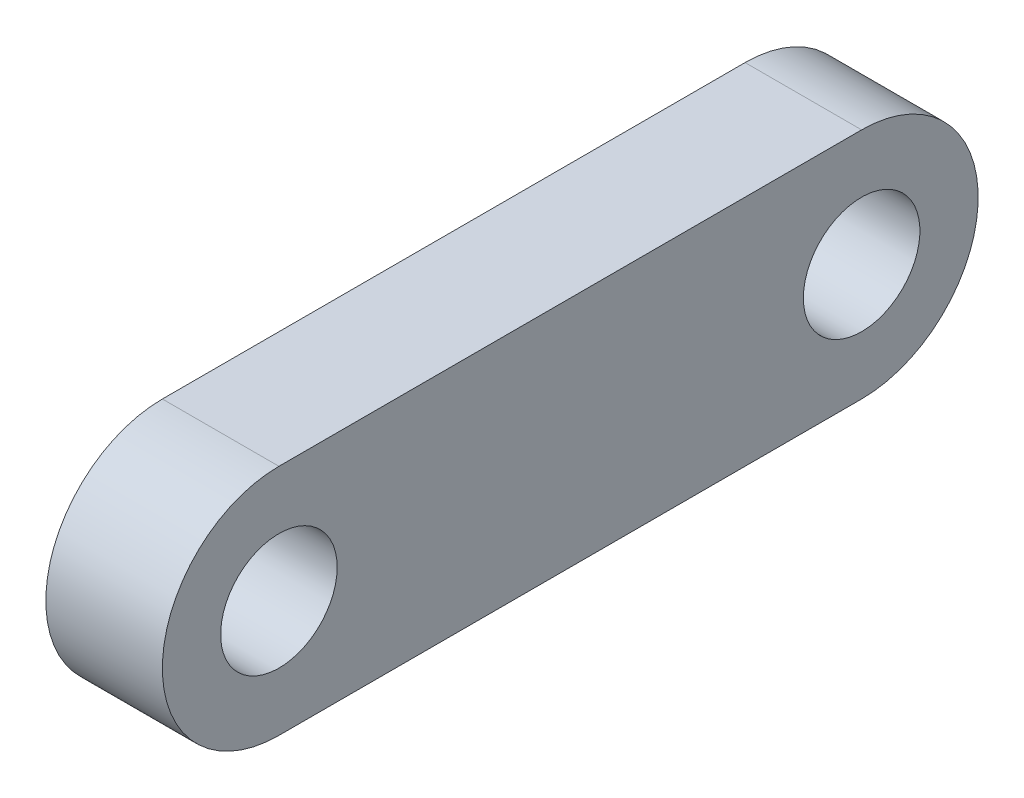
from build123d import *

# Parameters (mm, degrees)
SKETCH_1_R      = 4
EXTRUDE_1_DEPTH = 8


with BuildPart() as part:
    # 草图1 → 凸台-拉伸1 (new body)
    with BuildSketch(Plane(origin=(0, 0, 0), x_dir=(0, 0, -1), z_dir=(1, 0, 0))):
        with BuildLine():
            Line((20, 8), (-20, 8))
            ThreePointArc((-20, 8), (-28, 0), (-20, -8))
            Line((-20, -8), (20, -8))
            ThreePointArc((20, -8), (28, 0), (20, 8))
        make_face()
        with Locations((-20, 0)):
            Circle(SKETCH_1_R, mode=Mode.SUBTRACT)
        with Locations((20, 0)):
            Circle(SKETCH_1_R, mode=Mode.SUBTRACT)
    extrude(amount=EXTRUDE_1_DEPTH)


solid = part.part
